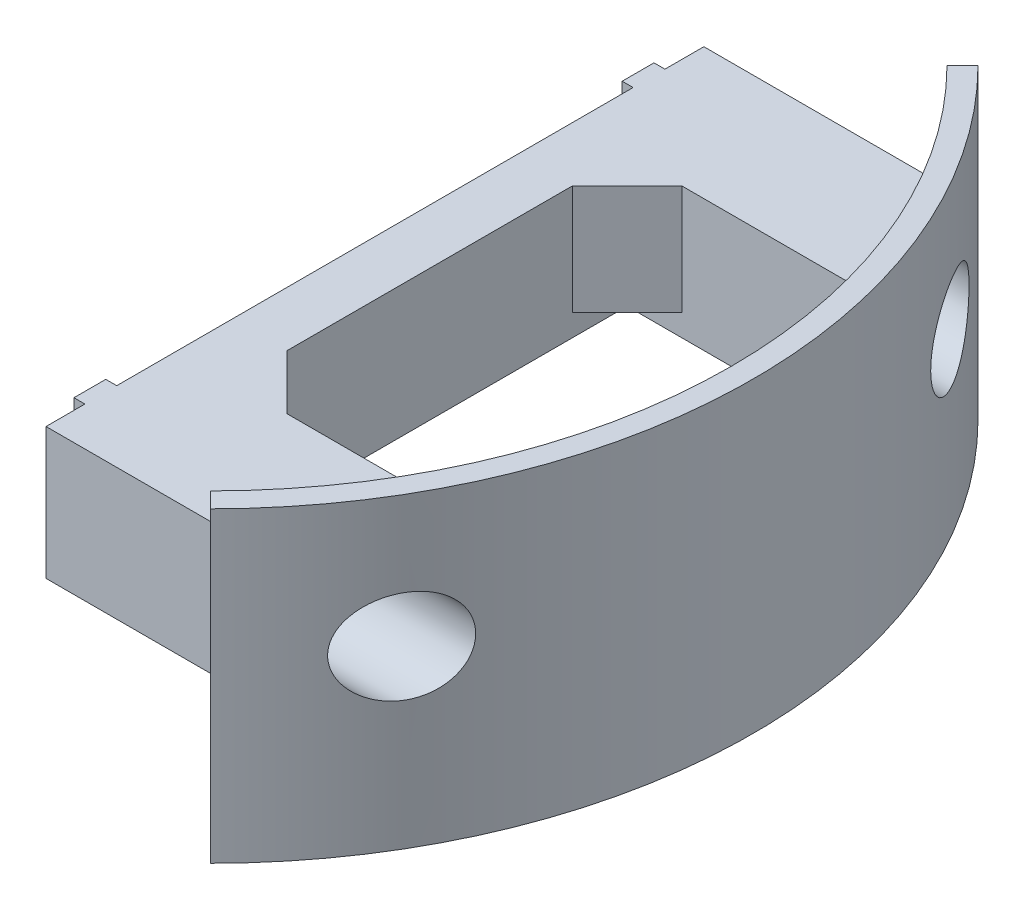
from build123d import *

# Parameters (mm, degrees)
SKETCH1_W           = 2
SKETCH1_H           = 40
MAIN_ANGLE          = 90
SUPPORT_DEPTH       = 12
SKETCH6_W           = 1
SKETCH6_H           = 2.9
FIX_2_DEPTH         = 12
SKETCH9_R           = 1.6
SKETCH9_W           = 60
SKETCH9_H           = 8
HOLES_DEPTH         = 7
SKETCH10_R          = 4.25
BIGHOLES_DEPTH      = 30.5
REINFORCEMENT_DEPTH = 10
SKETCH12_W          = 70.003571338
SKETCH12_H          = 12
SENSORWINDOW_DEPTH  = 35.5000001


with BuildPart() as part:
    # Sketch1 → Main (revolve, symmetric)
    with BuildSketch(Plane.XY) as main_sk:
        with Locations((48.5, 20)):
            Rectangle(SKETCH1_W, SKETCH1_H)
    revolve(axis=Axis((0, -0.284703924, 0), (0, 1, 0)), revolution_arc=MAIN_ANGLE / 2)
    revolve(main_sk.sketch, axis=Axis((0, -0.284703924, 0), (0, -1, 0)), revolution_arc=MAIN_ANGLE / 2)

    # Sketch2 → Support (add)
    with BuildSketch(Plane(origin=(0, 10, 0), x_dir=(-1, 0, 0), z_dir=(0, -1, 0))):
        with BuildLine():
            Line((-43.957365708, -18), (-20, -18))
            Line((-20, -18), (-20, 18))
            Line((-20, 18), (-43.957365708, 18))
            ThreePointArc((-43.957365708, 18), (-40.835530357, 24.263335724), (-36.827299657, 30))
            Line((-36.827299657, 30), (-15, 30))
            Line((-15, 30), (-15, -30))
            Line((-15, -30), (-36.827299657, -30))
            ThreePointArc((-36.827299657, -30), (-40.835530357, -24.263335724), (-43.957365708, -18))
        make_face()
    extrude(amount=-SUPPORT_DEPTH)

    # Sketch6 → Fix 2 (add)
    with BuildSketch(Plane(origin=(0, 10, 0), x_dir=(1, 0, 0), z_dir=(0, 1, 0))):
        with Locations((14.5, -25)):
            Rectangle(SKETCH6_W, SKETCH6_H)
        with Locations((14.5, 25)):
            Rectangle(SKETCH6_W, SKETCH6_H)
    extrude(amount=FIX_2_DEPTH)

    # Sketch9 → Holes (cut, through all)
    with BuildSketch(Plane(origin=(20, 0, 0), x_dir=(0, 0, -1), z_dir=(1, 0, 0))):
        with Locations((25, 16)):
            Circle(SKETCH9_R)
        with Locations((-25, 16)):
            Circle(SKETCH9_R)
        with Locations((0, 38)):
            Rectangle(SKETCH9_W, SKETCH9_H)
    extrude(amount=-HOLES_DEPTH, mode=Mode.SUBTRACT)

    # Sketch10 → BigHoles (cut, through all)
    with BuildSketch(Plane(origin=(20, 0, 0), x_dir=(0, 0, -1), z_dir=(1, 0, 0))):
        with Locations((25, 16)):
            Circle(SKETCH10_R)
        with Locations((-25, 16)):
            Circle(SKETCH10_R)
    extrude(amount=BIGHOLES_DEPTH, mode=Mode.SUBTRACT)

    # Sketch11 → Reinforcement (add)
    with BuildSketch(Plane(origin=(0, 22, 0), x_dir=(1, 0, 0), z_dir=(0, 1, 0))):
        Polygon((20, 18), (25, 18), (20, 13), align=None)
        Polygon((20, -18), (20, -13), (25, -18), align=None)
        Polygon((41.111278447, 18), (46.111278447, 18), (46.111278447, 13), align=None)
        Polygon((41.111278447, -18), (46.111278447, -18), (46.111278447, -11.401754251), align=None)
    extrude(amount=-REINFORCEMENT_DEPTH)

    # Sketch12 → SensorWindow (cut, through all)
    with BuildSketch(Plane.ZY.offset(-15)):
        with Locations((0, 34)):
            Rectangle(SKETCH12_W, SKETCH12_H)
    extrude(amount=-SENSORWINDOW_DEPTH, mode=Mode.SUBTRACT)


solid = part.part
